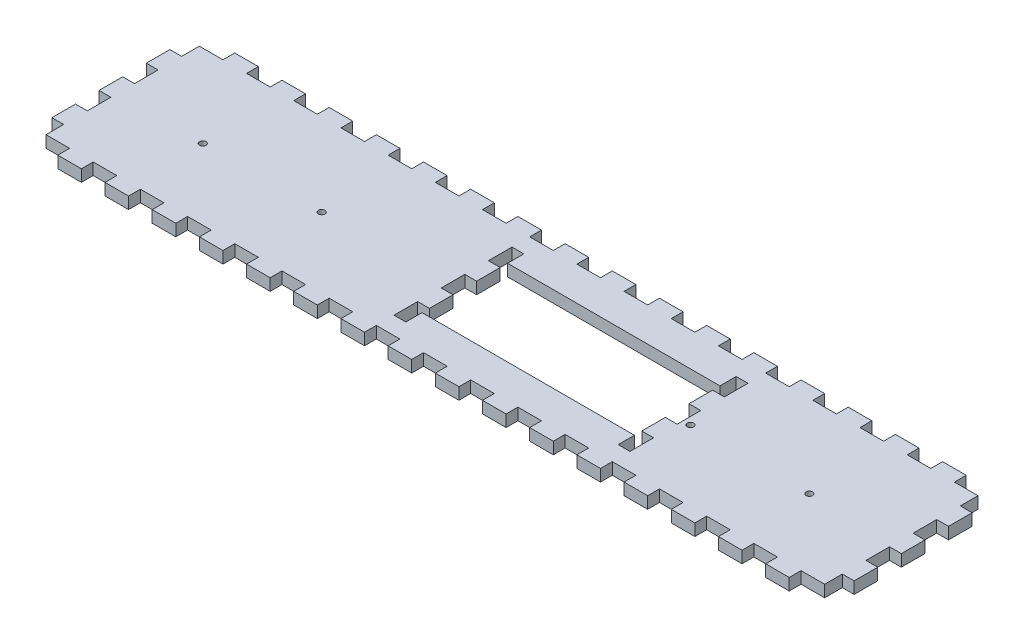
from build123d import *

# Parameters (mm, degrees)
SKETCH1_W           = 431.8
SKETCH1_H           = 95.25
BOSS_EXTRUDE1_DEPTH = 6.35
SKETCH2_W           = 12.7
SKETCH2_H           = 6.35
CUT_EXTRUDE1_DEPTH  = 7.35
LPATTERN1_COUNT     = 17
LPATTERN1_PITCH     = 25.4
SKETCH3_W           = 6.35
SKETCH3_H           = 6.35
CUT_EXTRUDE2_DEPTH  = 7.35
SKETCH5_W           = 6.35
SKETCH5_H           = 12.7
CUT_EXTRUDE4_DEPTH  = 7.35
LPATTERN2_COUNT     = 2
LPATTERN2_PITCH     = 25.4
LPATTERN2_COL_COUNT = 2
LPATTERN2_COL_PITCH = 25.4
SKETCH6_W           = 114.3
SKETCH6_H           = 46.0375
CUT_EXTRUDE5_DEPTH  = 7.35
SKETCH7_R           = 1.75
CUT_EXTRUDE6_DEPTH  = 7.35
SKETCH8_W           = 6.35
SKETCH8_H           = 9.525
SKETCH8_H_2         = 12.7
CUT_EXTRUDE7_DEPTH  = 7.35
LPATTERN3_COUNT     = 2
LPATTERN3_PITCH     = 425.45


with BuildPart() as part:
    # Sketch1 → Boss-Extrude1 (new body)
    with BuildSketch(Plane(origin=(0, 0, 0), x_dir=(1, 0, 0), z_dir=(0, 1, 0))):
        with Locations((215.9, 47.625)):
            Rectangle(SKETCH1_W, SKETCH1_H)
    extrude(amount=BOSS_EXTRUDE1_DEPTH)

    # Sketch2 → Cut-Extrude1 (cut, through all)
    with BuildSketch(Plane(origin=(0, 6.35, 0), x_dir=(1, 0, 0), z_dir=(0, 1, 0))):
        with Locations((12.7, 92.075)):
            Rectangle(SKETCH2_W, SKETCH2_H)
        with Locations((12.7, 3.175)):
            Rectangle(SKETCH2_W, SKETCH2_H)
    cut_extrude1 = extrude(amount=-CUT_EXTRUDE1_DEPTH, mode=Mode.SUBTRACT)

    # LPattern1: Cut-Extrude1 ×17
    with Locations(*[(i * LPATTERN1_PITCH, 0, 0) for i in range(1, LPATTERN1_COUNT)]):
        add(cut_extrude1, mode=Mode.SUBTRACT)

    # Sketch3 → Cut-Extrude2 (cut, through all)
    with BuildSketch(Plane(origin=(0, 6.35, 0), x_dir=(1, 0, 0), z_dir=(0, 1, 0))):
        with Locations((3.175, 92.075)):
            Rectangle(SKETCH3_W, SKETCH3_H)
        with Locations((3.175, 3.175)):
            Rectangle(SKETCH3_W, SKETCH3_H)
        with Locations((428.625, 92.075)):
            Rectangle(SKETCH3_W, SKETCH3_H)
        with Locations((428.625, 3.175)):
            Rectangle(SKETCH3_W, SKETCH3_H)
    extrude(amount=-CUT_EXTRUDE2_DEPTH, mode=Mode.SUBTRACT)

    # Sketch5 → Cut-Extrude4 (cut, through all)
    with BuildSketch(Plane(origin=(0, 6.35, 0), x_dir=(1, 0, 0), z_dir=(0, 1, 0))):
        with Locations((187.325, 47.625)):
            Rectangle(SKETCH5_W, SKETCH5_H)
        with Locations((307.975, 47.625)):
            Rectangle(SKETCH5_W, SKETCH5_H)
    cut_extrude4 = extrude(amount=-CUT_EXTRUDE4_DEPTH, mode=Mode.SUBTRACT)

    # LPattern2: Cut-Extrude4 ×2
    with Locations(*[(0, 0, -i * LPATTERN2_PITCH) for i in range(1, LPATTERN2_COUNT)]):
        add(cut_extrude4, mode=Mode.SUBTRACT)

    # LPattern2 col: Cut-Extrude4 ×2
    with Locations(*[(0, 0, i * LPATTERN2_COL_PITCH) for i in range(1, LPATTERN2_COL_COUNT)]):
        add(cut_extrude4, mode=Mode.SUBTRACT)

    # Sketch6 → Cut-Extrude5 (cut, through all)
    with BuildSketch(Plane(origin=(0, 6.35, 0), x_dir=(1, 0, 0), z_dir=(0, 1, 0))):
        with Locations((247.65, 47.625)):
            Rectangle(SKETCH6_W, SKETCH6_H)
    extrude(amount=-CUT_EXTRUDE5_DEPTH, mode=Mode.SUBTRACT)

    # Sketch7 → Cut-Extrude6 (cut, through all)
    with BuildSketch(Plane(origin=(0, 6.35, 0), x_dir=(1, 0, 0), z_dir=(0, 1, 0))):
        with Locations((52.65, 44.45)):
            Circle(SKETCH7_R)
        with Locations((116.65, 44.45)):
            Circle(SKETCH7_R)
        with Locations((315.15, 44.45)):
            Circle(SKETCH7_R)
        with Locations((379.15, 44.45)):
            Circle(SKETCH7_R)
    extrude(amount=-CUT_EXTRUDE6_DEPTH, mode=Mode.SUBTRACT)

    # Sketch8 → Cut-Extrude7 (cut, through all)
    with BuildSketch(Plane(origin=(0, 6.35, 0), x_dir=(1, 0, 0), z_dir=(0, 1, 0))):
        with Locations((3.175, 84.1375)):
            Rectangle(SKETCH8_W, SKETCH8_H)
        with Locations((3.175, 11.1125)):
            Rectangle(SKETCH8_W, SKETCH8_H)
        with Locations((3.175, 34.925)):
            Rectangle(SKETCH8_W, SKETCH8_H_2)
        with Locations((3.175, 60.325)):
            Rectangle(SKETCH8_W, SKETCH8_H_2)
    cut_extrude7 = extrude(amount=-CUT_EXTRUDE7_DEPTH, mode=Mode.SUBTRACT)

    # LPattern3: Cut-Extrude7 ×2
    with Locations(*[(i * LPATTERN3_PITCH, 0, 0) for i in range(1, LPATTERN3_COUNT)]):
        add(cut_extrude7, mode=Mode.SUBTRACT)


solid = part.part
